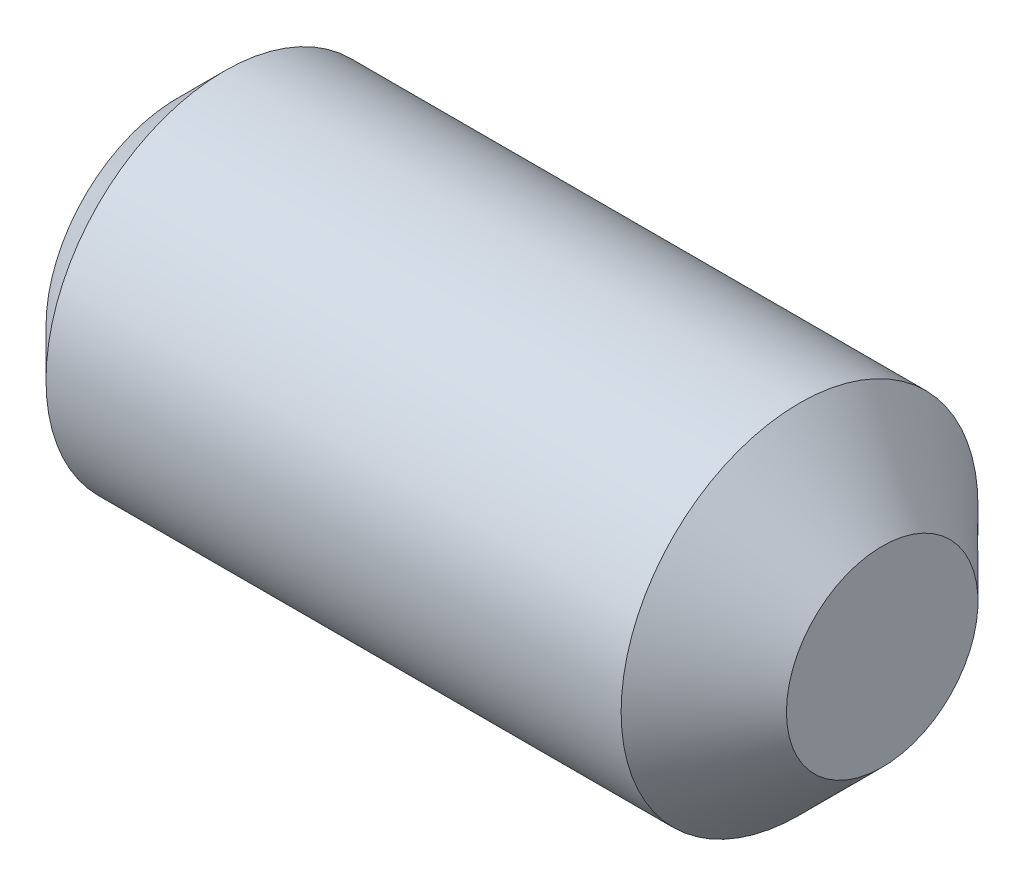
from build123d import *

# Parameters (mm, degrees)
HEX_2_DEPTH = 2.54


with BuildPart() as part:
    # BodySke → BaseBody (revolve)
    with BuildSketch(Plane.XY):
        Polygon((0, 0), (0, 1.78308), (0.62992, 2.413), (8.4074, 2.413), (9.525, 1.2954), (9.525, 0), align=None)
    revolve(axis=Axis((-12.7, 0, 0), (1, 0, 0)))

    # Sketch2 → Hex 2 (cut)
    with BuildSketch(Plane.ZY):
        Polygon((0.687041047, 1.18999), (-0.687041047, 1.18999), (-1.374082094, 0), (-0.687041047, -1.18999), (0.687041047, -1.18999), (1.374082094, 0), align=None)
    extrude(amount=-HEX_2_DEPTH, mode=Mode.SUBTRACT)


solid = part.part
